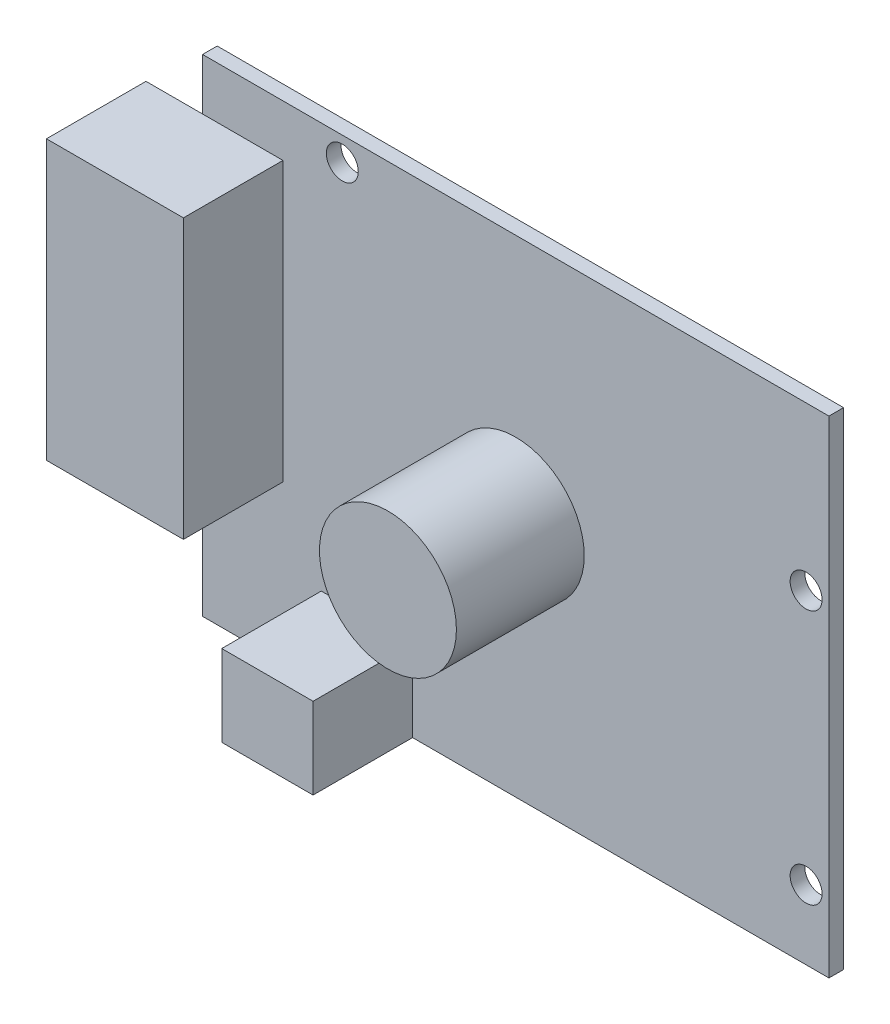
from build123d import *

# Parameters (mm, degrees)
SKETCH1_W           = 68.6
SKETCH1_H           = 53.3
BOSS_EXTRUDE1_DEPTH = 1.6
SKETCH2_W           = 15
SKETCH2_H           = 30.5
SKETCH2_W_2         = 10
SKETCH2_H_2         = 8.9
BOSS_EXTRUDE2_DEPTH = 10.9
SKETCH3_R           = 1.75
CUT_EXTRUDE1_DEPTH  = 2.6
SKETCH4_R           = 7.5
BOSS_EXTRUDE3_DEPTH = 14


with BuildPart() as part:
    # Sketch1 → Boss-Extrude1 (new body)
    with BuildSketch(Plane.XY):
        Rectangle(SKETCH1_W, SKETCH1_H)
    extrude(amount=BOSS_EXTRUDE1_DEPTH)

    # Sketch2 → Boss-Extrude2 (add)
    with BuildSketch(Plane.XY.offset(1.6)):
        with Locations((-33, 5.75)):
            Rectangle(SKETCH2_W, SKETCH2_H)
        with Locations((-16.3, -22.2)):
            Rectangle(SKETCH2_W_2, SKETCH2_H_2)
    extrude(amount=BOSS_EXTRUDE2_DEPTH)

    # Sketch3 → Cut-Extrude1 (cut, through all)
    with BuildSketch(Plane.XY.offset(1.6)):
        with Locations((-19, 24.05)):
            Circle(SKETCH3_R)
        with Locations((-20.3, -24.15)):
            Circle(SKETCH3_R)
        with Locations((31.8, -19.05)):
            Circle(SKETCH3_R)
        with Locations((31.8, 8.85)):
            Circle(SKETCH3_R)
    extrude(amount=-CUT_EXTRUDE1_DEPTH, mode=Mode.SUBTRACT)

    # Sketch4 → Boss-Extrude3 (add)
    with BuildSketch(Plane.XY.offset(1.6)):
        Circle(SKETCH4_R)
    extrude(amount=BOSS_EXTRUDE3_DEPTH)


solid = part.part
